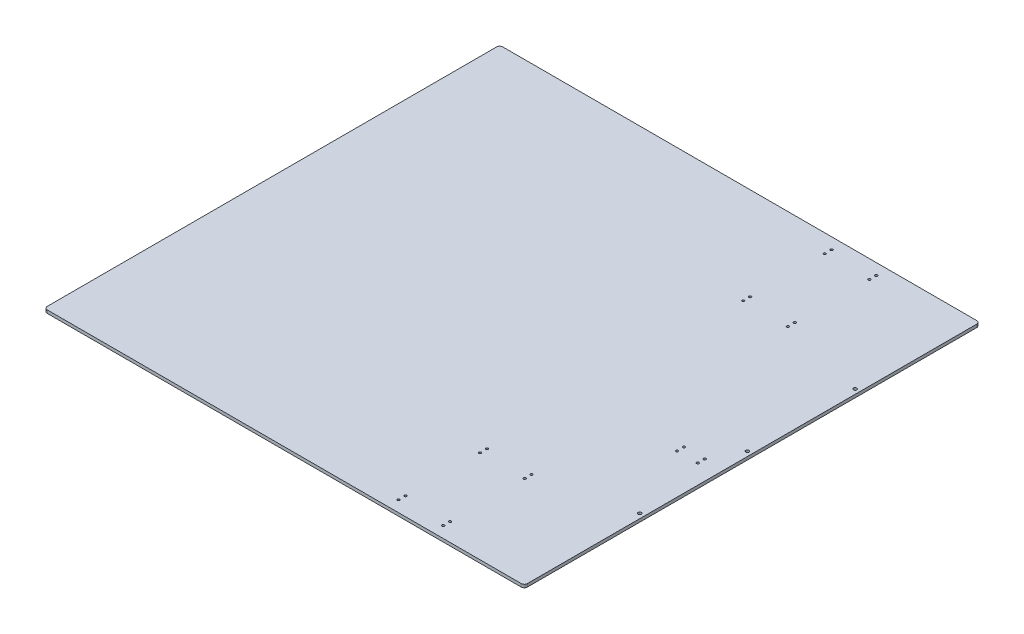
from build123d import *

# Parameters (mm, degrees)
SKETCH1_W           = 990.6
SKETCH1_H           = 6.35
BOSS_EXTRUDE1_DEPTH = 469.9
SKETCH2_R           = 2.4638
CUT_EXTRUDE1_DEPTH  = 7.35
SKETCH3_R           = 2.4638
CUT_EXTRUDE2_DEPTH  = 7.35
SKETCH4_R           = 3.3655
CUT_EXTRUDE3_DEPTH  = 7.35
FILLET1_R           = 6.35


with BuildPart() as part:
    # Sketch1 → Boss-Extrude1 (new body, symmetric)
    with BuildSketch(Plane.XY):
        with Locations((495.3, 3.175)):
            Rectangle(SKETCH1_W, SKETCH1_H)
    extrude(amount=BOSS_EXTRUDE1_DEPTH, both=True)

    # Sketch2 → Cut-Extrude1 (cut, through all)
    with BuildSketch(Plane(origin=(0, 6.35, 0), x_dir=(1, 0, 0), z_dir=(0, 1, 0))):
        with Locations((908.05, -72.263)):
            Circle(SKETCH2_R)
        with Locations((908.05, -58.039)):
            Circle(SKETCH2_R)
        with Locations((950.976, -72.263)):
            Circle(SKETCH2_R)
        with Locations((950.976, -58.039)):
            Circle(SKETCH2_R)
    extrude(amount=-CUT_EXTRUDE1_DEPTH, mode=Mode.SUBTRACT)

    # Sketch3 → Cut-Extrude2 (cut, through all)
    with BuildSketch(Plane(origin=(0, 6.35, 0), x_dir=(1, 0, 0), z_dir=(0, 1, 0))):
        with Locations((800.1, -446.786)):
            Circle(SKETCH3_R)
        with Locations((708.025, -446.786)):
            Circle(SKETCH3_R)
        with Locations((708.025, -432.562)):
            Circle(SKETCH3_R)
        with Locations((800.1, -432.562)):
            Circle(SKETCH3_R)
        with Locations((708.025, -264.414)):
            Circle(SKETCH3_R)
        with Locations((708.025, -278.638)):
            Circle(SKETCH3_R)
        with Locations((800.1, -264.414)):
            Circle(SKETCH3_R)
        with Locations((800.1, -278.638)):
            Circle(SKETCH3_R)
    cut_extrude2 = extrude(amount=-CUT_EXTRUDE2_DEPTH, mode=Mode.SUBTRACT)

    # Mirror1: Cut-Extrude2 across plane
    add(cut_extrude2.mirror(Plane.XY), mode=Mode.SUBTRACT)

    # Sketch4 → Cut-Extrude3 (cut, through all)
    with BuildSketch(Plane(origin=(0, 6.35, 0), x_dir=(1, 0, 0), z_dir=(0, 1, 0))):
        with Locations((981.075, 0)):
            Circle(SKETCH4_R)
        with Locations((981.075, 222.25)):
            Circle(SKETCH4_R)
        with Locations((981.075, -222.25)):
            Circle(SKETCH4_R)
    extrude(amount=-CUT_EXTRUDE3_DEPTH, mode=Mode.SUBTRACT)

    # Fillet1
    fillet1_edges = [part.edges().sort_by_distance(p)[0] for p in [
        (0, 3.175, 469.9),
        (0, 3.175, -469.9),
        (990.6, 3.175, -469.9),
        (990.6, 3.175, 469.9),
    ]]
    fillet(fillet1_edges, radius=FILLET1_R)


solid = part.part
